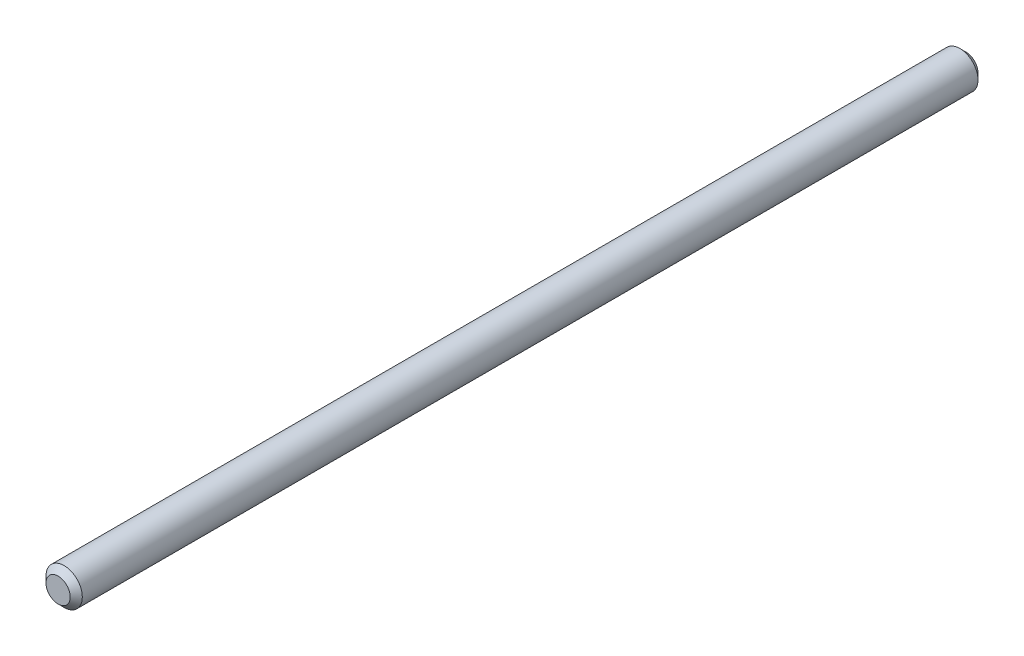
from build123d import *

# Parameters (mm, degrees)
SKETCH_1_R      = 3
EXTRUDE_1_DEPTH = 150
CHAMFER_1_SIZE  = 1


with BuildPart() as part:
    # 草圖1 → 填料-伸長1 (new body)
    with BuildSketch(Plane.XY):
        Circle(SKETCH_1_R)
    extrude(amount=EXTRUDE_1_DEPTH)

    # 導角1
    chamfer_1_edges = [part.edges().sort_by_distance(p)[0] for p in [
        (-3, 0, 0),
        (-3, 0, 150),
    ]]
    chamfer(chamfer_1_edges, length=CHAMFER_1_SIZE)


solid = part.part
